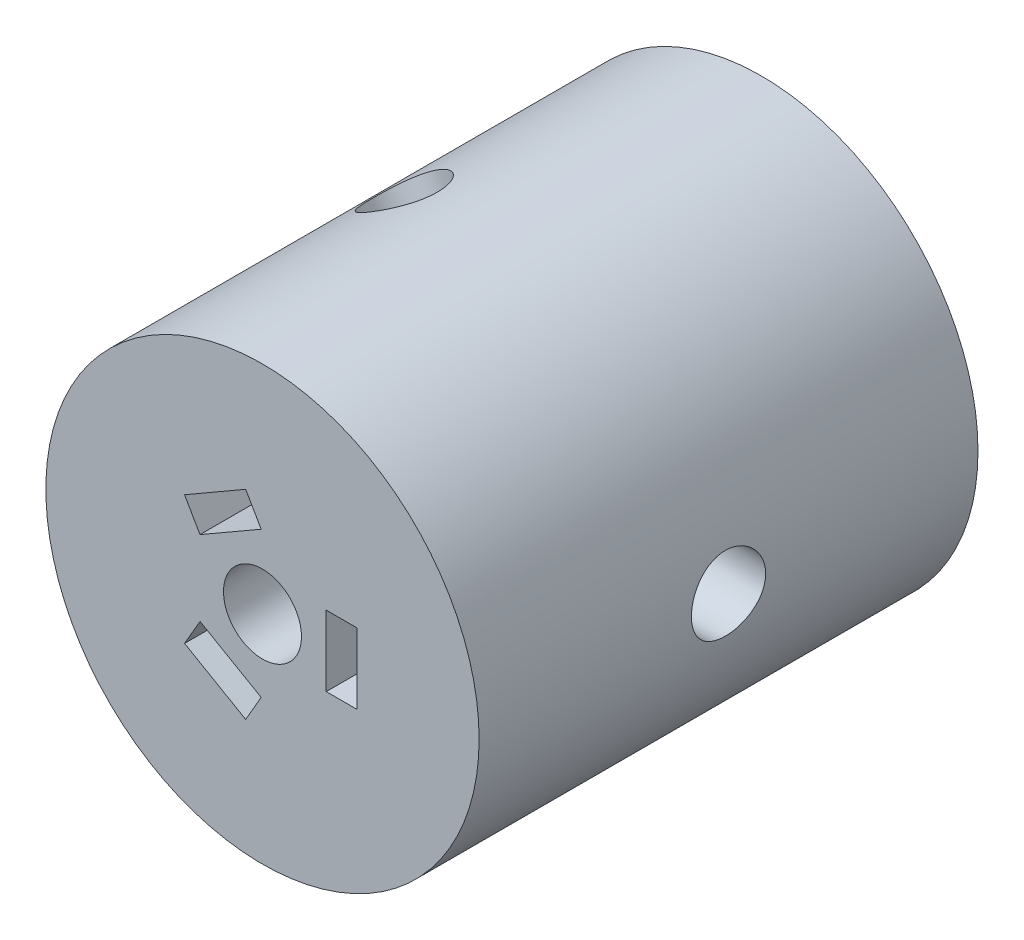
from build123d import *

# Parameters (mm, degrees)
SKETCH1_R           = 17.5
SKETCH1_R_2         = 3.15
BOSS_EXTRUDE1_DEPTH = 40.3
CUT_EXTRUDE1_DEPTH  = 23
CUT_EXTRUDE4_REACH  = 43.405
SKETCH8_R           = 1.65
CUT_EXTRUDE5_REACH  = 43.405
SKETCH10_R          = 1.65
SKETCH12_R          = 3
CUT_EXTRUDE6_DEPTH  = 5.35
SKETCH15_R          = 3
CUT_EXTRUDE8_DEPTH  = 5.35
CUT_EXTRUDE9_REACH  = 43.405
SKETCH17_R          = 1.65
CUT_EXTRUDE10_REACH = 43.405
SKETCH18_R          = 1.65
SKETCH19_R          = 3
CUT_EXTRUDE11_DEPTH = 5.35
CUT_EXTRUDE12_REACH = 37
SKETCH20_R          = 1.65
CUT_EXTRUDE13_REACH = 37
SKETCH21_R          = 1.65


with BuildPart() as part:
    # Sketch1 → Boss-Extrude1 (new body)
    with BuildSketch(Plane.XY):
        Circle(SKETCH1_R)
        Circle(SKETCH1_R_2, mode=Mode.SUBTRACT)
    extrude(amount=BOSS_EXTRUDE1_DEPTH)

    # Sketch2 → Cut-Extrude1 (cut)
    with BuildSketch(Plane.XY.offset(40.3)):
        Polygon((7.65, 0), (7.65, 2.85), (5.15, 2.85), (5.15, -2.85), (7.65, -2.85), align=None)
        Polygon((-3.825, -6.625094339), (-1.356827599, -8.050094339), (-0.106827599, -5.885030829), (-5.043172401, -3.035030829), (-6.293172401, -5.200094339), align=None)
        Polygon((-3.825, 6.625094339), (-6.293172401, 5.200094339), (-5.048242412, 3.035349353), (-0.105426694, 5.882604512), (-1.356827546, 8.050094369), align=None)
    extrude(amount=-CUT_EXTRUDE1_DEPTH, mode=Mode.SUBTRACT)

    # Sketch8 → Cut-Extrude4 (cut, up to next)
    with BuildSketch(Plane(origin=(-8.75, -15.155444566, 0), x_dir=(0, 0, -1), z_dir=(-0.5, -0.866025404, 0)), mode=Mode.PRIVATE) as cut_extrude4_sk1:
        with Locations((-20.15, 0)):
            Circle(SKETCH8_R)
    cut_extrude4_tool1 = extrude(cut_extrude4_sk1.sketch, amount=-CUT_EXTRUDE4_REACH, mode=Mode.PRIVATE) & part.part
    add(cut_extrude4_tool1.solids().sort_by_distance((-8.75, -15.155445, 20.15))[0], mode=Mode.SUBTRACT)

    # Sketch10 → Cut-Extrude5 (cut, up to next)
    with BuildSketch(Plane(origin=(-8.75, -15.155444566, 0), x_dir=(0, 0, -1), z_dir=(-0.5, -0.866025404, 0)), mode=Mode.PRIVATE) as cut_extrude5_sk1:
        with Locations((-20.15, 0)):
            Circle(SKETCH10_R)
    cut_extrude5_tool1 = extrude(cut_extrude5_sk1.sketch, amount=-CUT_EXTRUDE5_REACH, mode=Mode.PRIVATE) & part.part
    add(cut_extrude5_tool1.solids().sort_by_distance((-8.75, -15.155445, 20.15))[0], mode=Mode.SUBTRACT)

    # Sketch12 → Cut-Extrude6 (cut)
    with BuildSketch(Plane(origin=(-8.75, -15.155444566, 0), x_dir=(0, 0, -1), z_dir=(-0.5, -0.866025404, 0))):
        with Locations((-20.15, 0)):
            Circle(SKETCH12_R)
    extrude(amount=-CUT_EXTRUDE6_DEPTH, mode=Mode.SUBTRACT)

    # Sketch15 → Cut-Extrude8 (cut)
    with BuildSketch(Plane(origin=(-8.75, 15.155444566, 0), x_dir=(0, 0, -1), z_dir=(-0.5, 0.866025404, 0))):
        with Locations((-20.15, 0)):
            Circle(SKETCH15_R)
    extrude(amount=-CUT_EXTRUDE8_DEPTH, mode=Mode.SUBTRACT)

    # Sketch17 → Cut-Extrude9 (cut, up to next)
    with BuildSketch(Plane(origin=(-8.75, 15.155444566, 0), x_dir=(0, 0, -1), z_dir=(-0.5, 0.866025404, 0)), mode=Mode.PRIVATE) as cut_extrude9_sk1:
        with Locations((-20.15, 0)):
            Circle(SKETCH17_R)
    cut_extrude9_tool1 = extrude(cut_extrude9_sk1.sketch, amount=-CUT_EXTRUDE9_REACH, mode=Mode.PRIVATE) & part.part
    add(cut_extrude9_tool1.solids().sort_by_distance((-8.75, 15.155445, 20.15))[0], mode=Mode.SUBTRACT)

    # Sketch18 → Cut-Extrude10 (cut, up to next)
    with BuildSketch(Plane(origin=(-8.75, 15.155444566, 0), x_dir=(0, 0, -1), z_dir=(-0.5, 0.866025404, 0)), mode=Mode.PRIVATE) as cut_extrude10_sk1:
        with Locations((-20.15, 0)):
            Circle(SKETCH18_R)
    cut_extrude10_tool1 = extrude(cut_extrude10_sk1.sketch, amount=-CUT_EXTRUDE10_REACH, mode=Mode.PRIVATE) & part.part
    add(cut_extrude10_tool1.solids().sort_by_distance((-8.75, 15.155445, 20.15))[0], mode=Mode.SUBTRACT)

    # Sketch19 → Cut-Extrude11 (cut)
    with BuildSketch(Plane(origin=(17.5, 0, 0), x_dir=(0, 0, -1), z_dir=(1, 0, 0))):
        with Locations((-20.15, 0)):
            Circle(SKETCH19_R)
    extrude(amount=-CUT_EXTRUDE11_DEPTH, mode=Mode.SUBTRACT)

    # Sketch20 → Cut-Extrude12 (cut, up to next)
    with BuildSketch(Plane(origin=(17.5, 0, 0), x_dir=(0, 0, -1), z_dir=(1, 0, 0)), mode=Mode.PRIVATE) as cut_extrude12_sk1:
        with Locations((-20.15, 0)):
            Circle(SKETCH20_R)
    cut_extrude12_tool1 = extrude(cut_extrude12_sk1.sketch, amount=-CUT_EXTRUDE12_REACH, mode=Mode.PRIVATE) & part.part
    add(cut_extrude12_tool1.solids().sort_by_distance((17.5, 0, 20.15))[0], mode=Mode.SUBTRACT)

    # Sketch21 → Cut-Extrude13 (cut, up to next)
    with BuildSketch(Plane(origin=(17.5, 0, 0), x_dir=(0, 0, -1), z_dir=(1, 0, 0)), mode=Mode.PRIVATE) as cut_extrude13_sk1:
        with Locations((-20.15, 0)):
            Circle(SKETCH21_R)
    cut_extrude13_tool1 = extrude(cut_extrude13_sk1.sketch, amount=-CUT_EXTRUDE13_REACH, mode=Mode.PRIVATE) & part.part
    add(cut_extrude13_tool1.solids().sort_by_distance((17.5, 0, 20.15))[0], mode=Mode.SUBTRACT)


solid = part.part
